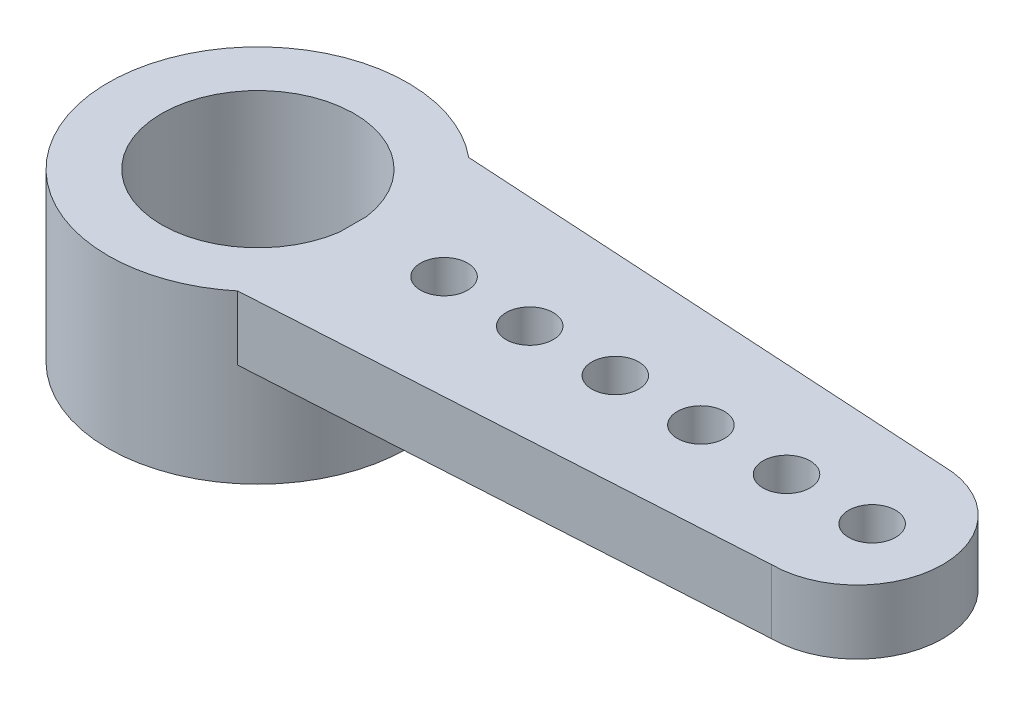
from build123d import *

# Parameters (mm, degrees)
SKETCH1_R           = 3.5
SKETCH1_R_2         = 2.25
BOSS_EXTRUDE1_DEPTH = 3.9
SKETCH2_R           = 2
BOSS_EXTRUDE2_DEPTH = 1.5
SKETCH3_R           = 0.55
CUT_EXTRUDE1_DEPTH  = 1.5
LPATTERN1_COUNT     = 6
LPATTERN1_PITCH     = 2


with BuildPart() as part:
    # Sketch1 → Boss-Extrude1 (new body)
    with BuildSketch(Plane(origin=(0, 0, 0), x_dir=(1, 0, 0), z_dir=(0, 1, 0))):
        Circle(SKETCH1_R)
        Circle(SKETCH1_R_2, mode=Mode.SUBTRACT)
    extrude(amount=-BOSS_EXTRUDE1_DEPTH)

    # Sketch2 → Boss-Extrude2 (add)
    with BuildSketch(Plane(origin=(0, 0, 0), x_dir=(1, 0, 0), z_dir=(0, 1, 0))):
        with BuildLine():
            ThreePointArc((14, -2), (12, 0), (14, 2))
            Line((14, 2), (2.227105745, 2.7))
            Line((2.227105745, 2.7), (2.227105745, -2.7))
            Line((2.227105745, -2.7), (14, -2))
        make_face()
        with Locations((14, 0)):
            Circle(SKETCH2_R)
    extrude(amount=-BOSS_EXTRUDE2_DEPTH)

    # Sketch3 → Cut-Extrude1 (cut)
    with BuildSketch(Plane(origin=(0, 0, 0), x_dir=(1, 0, 0), z_dir=(0, 1, 0))):
        with Locations((14.35, 0)):
            Circle(SKETCH3_R)
    cut_extrude1 = extrude(amount=-CUT_EXTRUDE1_DEPTH, mode=Mode.SUBTRACT)

    # LPattern1: Cut-Extrude1 ×6
    with Locations(*[(-i * LPATTERN1_PITCH, 0, 0) for i in range(1, LPATTERN1_COUNT)]):
        add(cut_extrude1, mode=Mode.SUBTRACT)


solid = part.part
